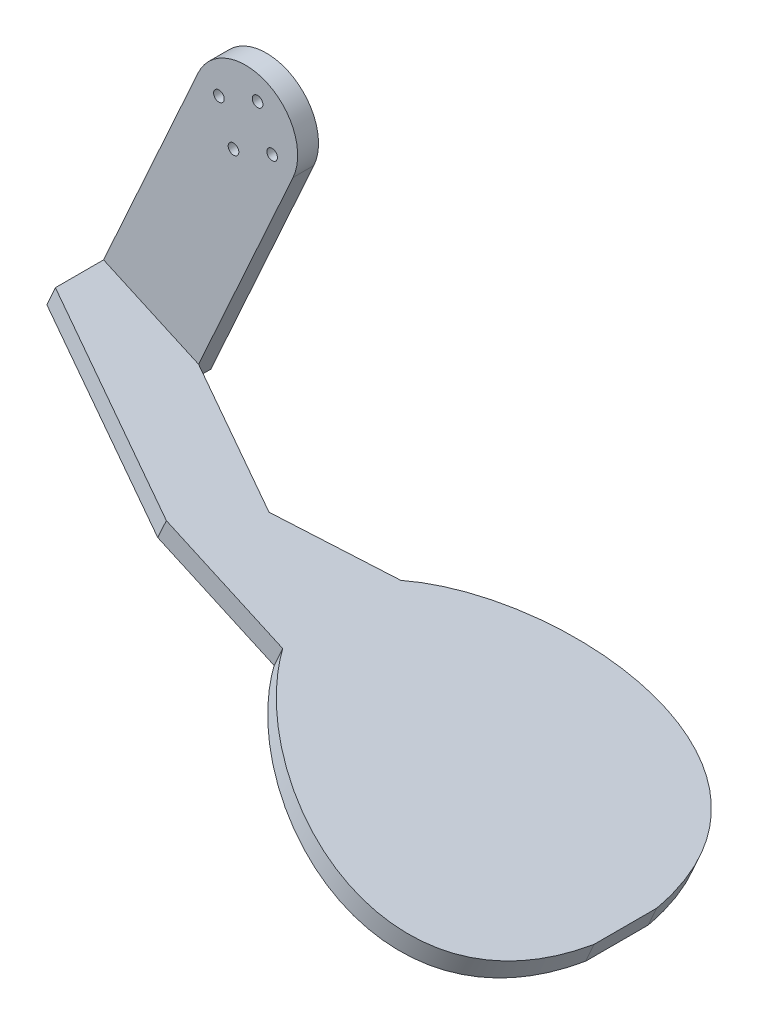
from build123d import *

# Parameters (mm, degrees)
SKETCH2_R           = 10
SKETCH2_R_2         = 1.275
BOSS_EXTRUDE1_DEPTH = 3
SKETCH3_R           = 1.275
BOSS_EXTRUDE2_DEPTH = 5
BOSS_EXTRUDE3_DEPTH = 5


with BuildPart() as part:
    # Sketch2 → Boss-Extrude1 (new body)
    with BuildSketch(Plane.XY):
        Circle(SKETCH2_R)
        with Locations((2.883236265, 6.378632192)):
            Circle(SKETCH2_R_2, mode=Mode.SUBTRACT)
        with Locations((6.378632192, -2.883236265)):
            Circle(SKETCH2_R_2, mode=Mode.SUBTRACT)
        with Locations((-2.883236265, -6.378632192)):
            Circle(SKETCH2_R_2, mode=Mode.SUBTRACT)
        with Locations((-6.378632192, 2.883236265)):
            Circle(SKETCH2_R_2, mode=Mode.SUBTRACT)
    extrude(amount=BOSS_EXTRUDE1_DEPTH)

    # Sketch3 → Boss-Extrude2 (add)
    with BuildSketch(Plane.XY.offset(3)):
        with BuildLine():
            Line((11.390414628, -5.148636188), (-13.323039072, -59.822626404))
            Line((-13.323039072, -59.822626404), (-36.103868329, -49.525354029))
            Line((-36.103868329, -49.525354029), (-11.390414628, 5.148636188))
            ThreePointArc((-11.390414628, 5.148636188), (5.148636188, 11.390414628), (11.390414628, -5.148636188))
        make_face()
        with Locations((2.883236265, 6.378632192)):
            Circle(SKETCH3_R, mode=Mode.SUBTRACT)
        with Locations((6.378632192, -2.883236265)):
            Circle(SKETCH3_R, mode=Mode.SUBTRACT)
        with Locations((-2.883236265, -6.378632192)):
            Circle(SKETCH3_R, mode=Mode.SUBTRACT)
        with Locations((-6.378632192, 2.883236265)):
            Circle(SKETCH3_R, mode=Mode.SUBTRACT)
    extrude(amount=-BOSS_EXTRUDE2_DEPTH)

    # Sketch4 → Boss-Extrude3 (add)
    with BuildSketch(Plane(origin=(-24.7134537, -54.673990217, 0), x_dir=(-0.91123317, 0.411890895, 0), z_dir=(-0.411890895, -0.91123317, 0))):
        with BuildLine():
            Line((-64.737964533, -30.42203086), (-34.115083994, -30.42203086))
            Line((-34.115083994, -30.42203086), (12.5, -14.551275179))
            Line((12.5, -14.551275179), (12.5, -3))
            Line((12.5, -3), (-12.5, -3))
            Line((-12.5, -3), (-42.101583528, -13.07827209))
            Line((-42.101583528, -13.07827209), (-64.737964533, -2.10203086))
            add(Edge.make_bspline(
                [(-64.737964533, -2.10203086), (-81.761805894, 22.419892021), (-132.619227666, 37.649465731), (-139.381607577, -8.76203086)],
                knots=[0, 0, 0, 0, 1, 1, 1, 1], degree=3))
            Line((-139.381607577, -8.76203086), (-139.381607577, -23.76203086))
            add(Edge.make_bspline(
                [(-64.737964533, -30.42203086), (-81.761805894, -54.943953742), (-132.619227666, -70.173527452), (-139.381607577, -23.76203086)],
                knots=[0, 0, 0, 0, 1, 1, 1, 1], degree=3))
        make_face()
    extrude(amount=-BOSS_EXTRUDE3_DEPTH)


solid = part.part
